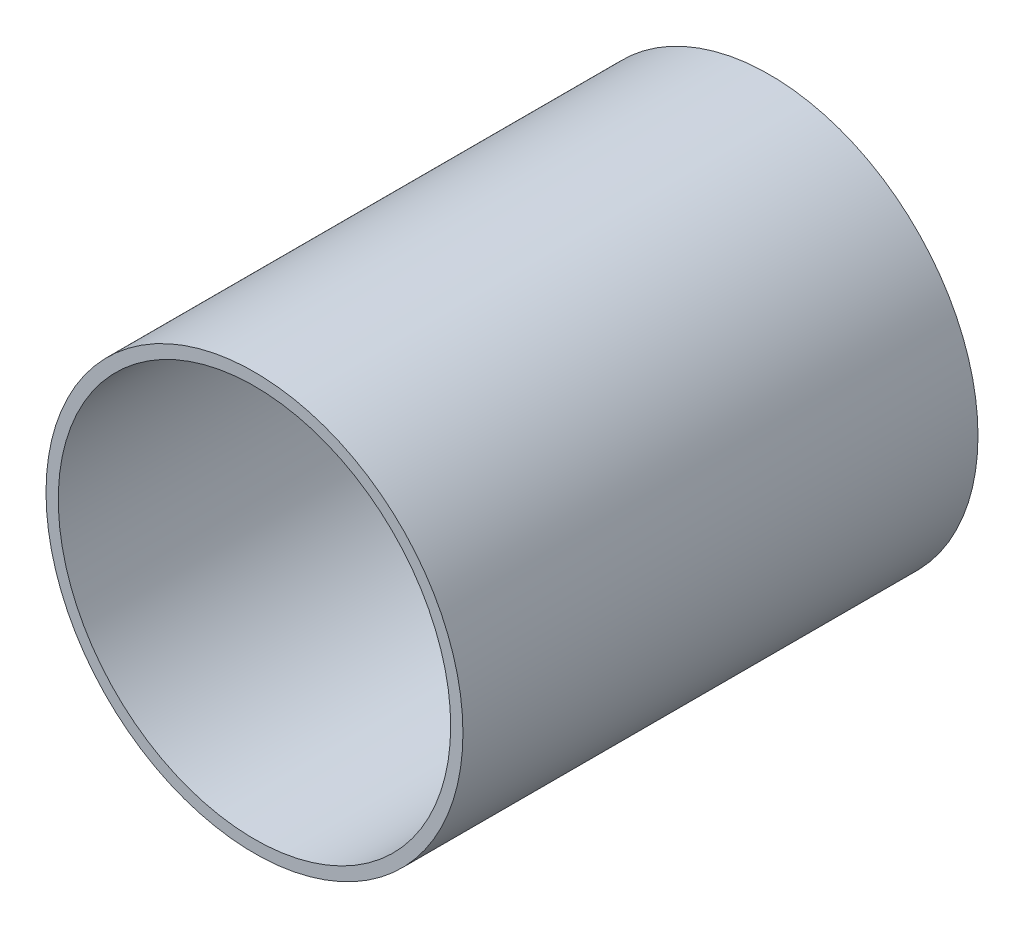
from build123d import *

# Parameters (mm, degrees)
SKETCH1_R                                           = 53.975
BOSS_EXTRUDE1_DEPTH                                 = 6.35
CSK_FOR_1_4_FLAT_HEAD_MACHINE_SCREW_100_D           = 6.7564
CSK_FOR_1_4_FLAT_HEAD_MACHINE_SCREW_100_CSINK_D     = 12.8778
CSK_FOR_1_4_FLAT_HEAD_MACHINE_SCREW_100_CSINK_ANGLE = 100
SKETCH4_R                                           = 53.975
SKETCH4_R_2                                         = 50.8
BOSS_EXTRUDE2_DEPTH                                 = 127


with BuildPart() as part:
    # Sketch1 → Boss-Extrude1 (new body)
    with BuildSketch(Plane.XY):
        Circle(SKETCH1_R)
    extrude(amount=BOSS_EXTRUDE1_DEPTH)

    # CSK for 1/4 Flat Head Machine Screw (100)1 (through all)
    with Locations(Plane.XY.offset(6.35)):
        with Locations((0, 0)):
            CounterSinkHole(CSK_FOR_1_4_FLAT_HEAD_MACHINE_SCREW_100_D / 2, CSK_FOR_1_4_FLAT_HEAD_MACHINE_SCREW_100_CSINK_D / 2, counter_sink_angle=CSK_FOR_1_4_FLAT_HEAD_MACHINE_SCREW_100_CSINK_ANGLE)

    # Sketch4 → Boss-Extrude2 (add)
    with BuildSketch(Plane.XY.offset(6.35)):
        Circle(SKETCH4_R)
        Circle(SKETCH4_R_2, mode=Mode.SUBTRACT)
    extrude(amount=BOSS_EXTRUDE2_DEPTH)


solid = part.part
